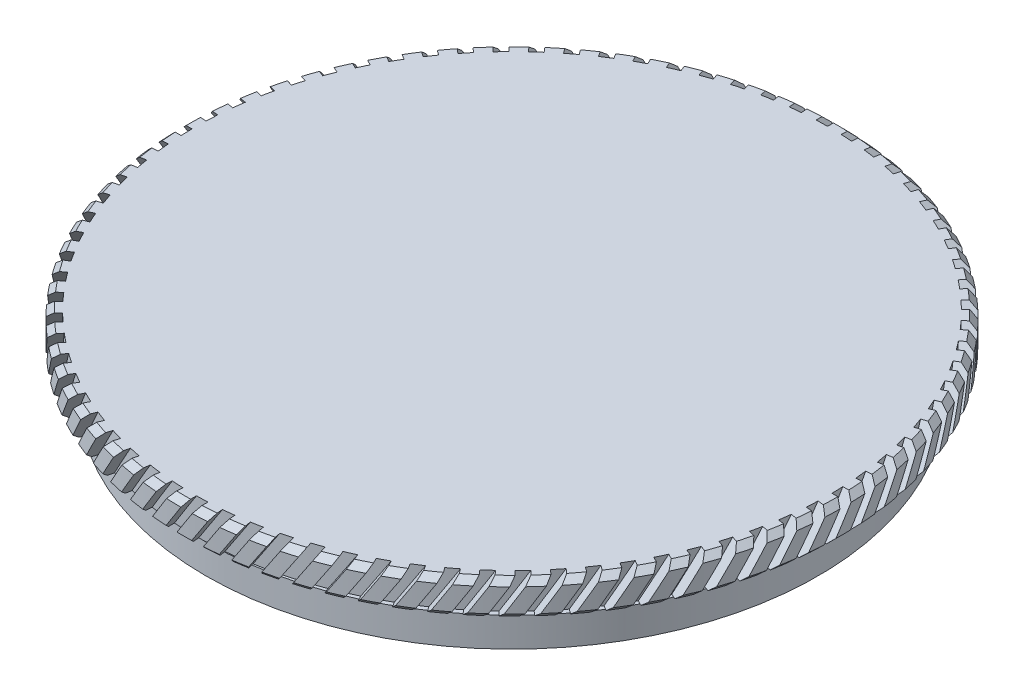
from build123d import *

# Parameters (mm, degrees)
CHAMFER_1_SIZE           = 0.5
CUT_EXTRUDE_1_REACH      = 87.237
CUT_EXTRUDE_1_END_RADIUS = 27
CUT_EXTRUDE_START        = 40
PATTERN_CIRCULAR_2_COUNT = 80


with BuildPart() as part:
    # 草图1 → 旋转2 (revolve)
    with BuildSketch(Plane.XY, mode=Mode.PRIVATE) as revolve_2_sk:
        Polygon((0, 21.871257405), (28, 21.871257405), (28, 18.871257405), (25.5, 18.871257405), (25.5, 17.871257405), (26, 17.871257405), (26, 15.371257405), (24, 15.371257405), (24, 18.871257405), (0, 18.871257405), align=None)
    revolve(revolve_2_sk.sketch.rotate(Axis((0, 66.628762136, 0), (0, -1, 0)), 90), axis=Axis((0, 66.628762136, 0), (0, -1, 0)))

    # 倒角1
    chamfer_1_edges = [part.edges().sort_by_distance(p)[0] for p in [
        (0, 21.871257405, -28),
        (0, 18.871257405, -28),
    ]]
    chamfer(chamfer_1_edges, length=CHAMFER_1_SIZE)

    # 切除-拉伸1: up to this cylinder (the profile starts outside it)
    cut_extrude_1_end = Plane(origin=(0, 18.072086, 0), z_dir=(0, 1, 0)) * Cylinder(CUT_EXTRUDE_1_END_RADIUS, 229.474, mode=Mode.PRIVATE)
    # 草图2 → 切除-拉伸1 (cut, up to the surface)
    with BuildSketch(Plane.XY.offset(CUT_EXTRUDE_START), mode=Mode.PRIVATE) as cut_extrude_1_sk1:
        Polygon((1.108168834, 23.303253722), (-5.339513804, 13.273525174), (-4.666571024, 12.840919101), (1.781111614, 22.870647649), align=None)
    cut_extrude_1_tool1 = extrude(cut_extrude_1_sk1.sketch, amount=-CUT_EXTRUDE_1_REACH, mode=Mode.PRIVATE) - cut_extrude_1_end
    cut_extrude_1 = cut_extrude_1_tool1.solids().sort_by_distance((-1.779201, 18.072086, 40))[0]
    add(cut_extrude_1, mode=Mode.SUBTRACT)

    # 阵列(圆周)2: 切除-拉伸1 ×80 about axis
    pattern_circular_2_axis = Axis((0, 0, 0), (0, 1, 0))
    for i in range(1, PATTERN_CIRCULAR_2_COUNT):
        add(cut_extrude_1.rotate(pattern_circular_2_axis, i * 360 / PATTERN_CIRCULAR_2_COUNT), mode=Mode.SUBTRACT)


solid = part.part
